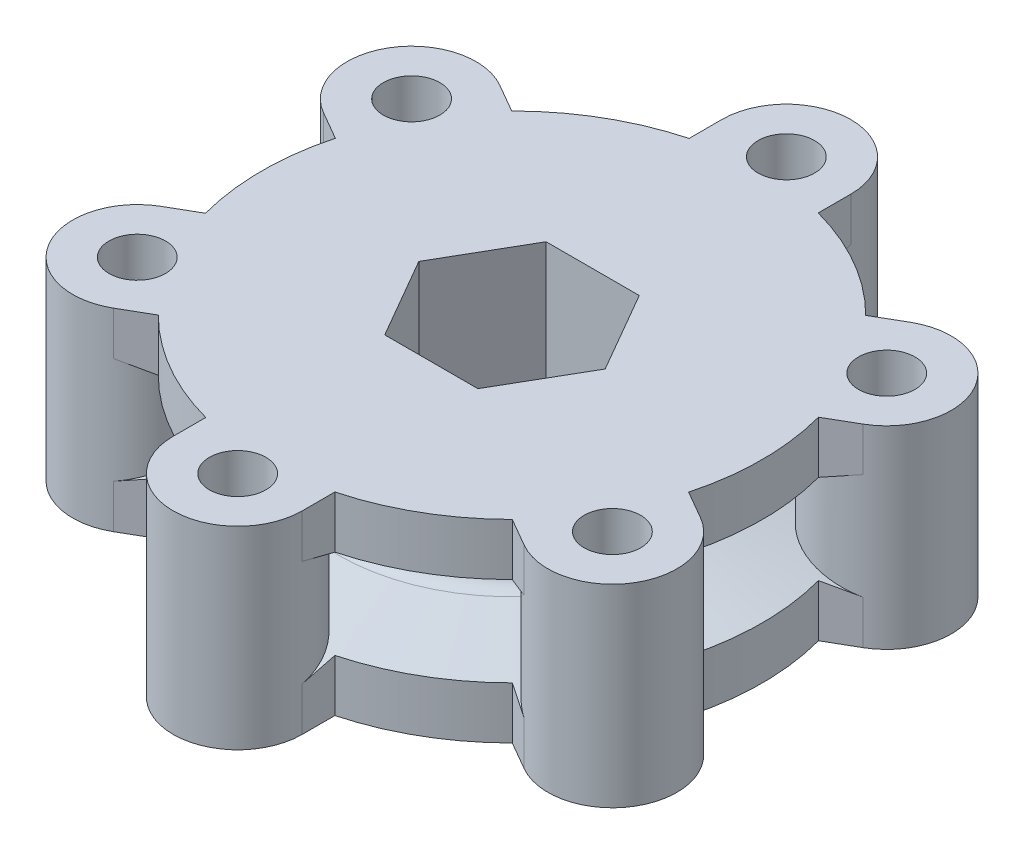
from build123d import *

# Parameters (mm, degrees)
SKETCH1_R           = 31.75
BOSS_EXTRUDE1_DEPTH = 7.62
CUT_EXTRUDE4_DEPTH  = 0.635
CIRPATTERN2_COUNT   = 20
BOSS_EXTRUDE2_REACH = 46.031
SKETCH5_R           = 5.08
SKETCH5_R_2         = 2.2225
BOSS_EXTRUDE6_REACH = 46.031
SKETCH12_R          = 5.08
SKETCH17_R          = 2.2225
CUT_EXTRUDE5_DEPTH  = 43.006102077
CIRPATTERN1_COUNT   = 3
BOSS_EXTRUDE9_REACH = 40.845
SKETCH18_R          = 12.7
FILLET5_R           = 1.27
CUT_EXTRUDE7_DEPTH  = 39.84476118


with BuildPart() as part:
    # Sketch1 → Boss-Extrude1 (new, symmetric)
    with BuildSketch(Plane(origin=(0, 0, 0), x_dir=(1, 0, 0), z_dir=(0, 1, 0))):
        Circle(SKETCH1_R)
    extrude(amount=BOSS_EXTRUDE1_DEPTH, both=True)

    # Sketch9 → Cut-Extrude4 (cut)
    with BuildSketch(Plane.ZY.offset(31.75)):
        Polygon((-0.635, -7.62), (0.635, -7.62), (0.635, 0), (0.635, 7.62), (-0.635, 7.62), (-0.635, 0), align=None)
    cut_extrude4 = extrude(amount=-CUT_EXTRUDE4_DEPTH, mode=Mode.SUBTRACT)

    # CirPattern2: Cut-Extrude4 ×20 about axis
    cirpattern2_axis = Axis((0, -7.62, 0), (0, 1, 0))
    for i in range(1, CIRPATTERN2_COUNT):
        add(cut_extrude4.rotate(cirpattern2_axis, i * 360 / CIRPATTERN2_COUNT), mode=Mode.SUBTRACT)

    # Sketch4 → Cut-Revolve2 (revolve, cut)
    with BuildSketch(Plane.XY):
        Polygon((-31.75, -7.62), (-29.21, -7.62), (-29.21, -6.0325), (-6.35, 0), (-29.21, 6.0325), (-29.21, 7.62), (-31.75, 7.62), align=None)
    revolve(axis=Axis((0, -9.0805, 0), (0, 1, 0)), mode=Mode.SUBTRACT)

    # Sketch5 → Boss-Extrude2 (add, up to next)
    with BuildSketch(Plane(origin=(0, 7.62, 0), x_dir=(1, 0, 0), z_dir=(0, 1, 0)), mode=Mode.PRIVATE) as boss_extrude2_sk1:
        with Locations((0, 21.59)):
            Circle(SKETCH5_R)
        with Locations((0, 21.59)):
            Circle(SKETCH5_R_2, mode=Mode.SUBTRACT)
    boss_extrude2_tool1 = extrude(boss_extrude2_sk1.sketch, amount=-BOSS_EXTRUDE2_REACH, mode=Mode.PRIVATE) - part.part
    boss_extrude2 = boss_extrude2_tool1.solids().sort_by_distance((-4.936316, 7.62, -21.59))[0]
    add(boss_extrude2)

    # Sketch12 → Boss-Extrude6 (add, up to next)
    with BuildSketch(Plane(origin=(0, 7.62, 0), x_dir=(1, 0, 0), z_dir=(0, 1, 0)), mode=Mode.PRIVATE) as boss_extrude6_sk1:
        with Locations((-18.697488468, 10.795)):
            Circle(SKETCH12_R)
    boss_extrude6_tool1 = extrude(boss_extrude6_sk1.sketch, amount=-BOSS_EXTRUDE6_REACH, mode=Mode.PRIVATE) - part.part
    boss_extrude6 = boss_extrude6_tool1.solids().sort_by_distance((-18.697488, 7.62, -10.795))[0]
    add(boss_extrude6)

    # Sketch17 → Cut-Extrude5 (cut, symmetric)
    with BuildSketch(Plane(origin=(0, 0, 0), x_dir=(1, 0, 0), z_dir=(0, 1, 0))):
        with Locations((0, 21.59)):
            Circle(SKETCH17_R)
        with Locations((-18.697488468, 10.795)):
            Circle(SKETCH17_R)
        with Locations((-18.697488468, -10.795)):
            Circle(SKETCH17_R)
        with BuildLine():
            Line((-23.096897519, -13.335), (-25.296602045, -14.605))
            ThreePointArc((-25.296602045, -14.605), (-25.296602045, 14.605), (0, 29.21))
            Line((0, 29.21), (0, 26.67))
            ThreePointArc((0, 26.67), (-3.592102448, 25.182102448), (-5.08, 21.59))
            Line((-5.08, 21.59), (-5.08, 19.018223497))
            ThreePointArc((-5.08, 19.018223497), (-9.8425, 17.047710073), (-13.930264684, 13.9085208))
            Line((-13.930264684, 13.9085208), (-16.157488468, 15.194409051))
            ThreePointArc((-16.157488468, 15.194409051), (-23.096897519, 13.335), (-21.237488468, 6.395590949))
            Line((-21.237488468, 6.395590949), (-19.010264684, 5.109702698))
            ThreePointArc((-19.010264684, 5.109702698), (-19.685, 0), (-19.010264684, -5.109702698))
            Line((-19.010264684, -5.109702698), (-21.237488468, -6.395590949))
            ThreePointArc((-21.237488468, -6.395590949), (-23.604391665, -9.480199251), (-23.096897519, -13.335))
        make_face()
    cut_extrude5 = extrude(amount=CUT_EXTRUDE5_DEPTH, both=True, mode=Mode.SUBTRACT)

    # CirPattern1: Boss-Extrude2, Boss-Extrude6, Cut-Extrude5 ×3 about axis
    cirpattern1_axis = Axis((0, 6.0325, 0), (0, -1, 0))
    add([boss_extrude2.rotate(cirpattern1_axis, i * 360 / CIRPATTERN1_COUNT) for i in range(1, CIRPATTERN1_COUNT)])
    add([boss_extrude6.rotate(cirpattern1_axis, i * 360 / CIRPATTERN1_COUNT) for i in range(1, CIRPATTERN1_COUNT)])
    add([cut_extrude5.rotate(cirpattern1_axis, i * 360 / CIRPATTERN1_COUNT) for i in range(1, CIRPATTERN1_COUNT)], mode=Mode.SUBTRACT)

    # Sketch18 → Boss-Extrude9 (add, up to next)
    with BuildSketch(Plane.XZ.offset(7.62), mode=Mode.PRIVATE) as boss_extrude9_sk1:
        Circle(SKETCH18_R)
    boss_extrude9_tool1 = extrude(boss_extrude9_sk1.sketch, amount=-BOSS_EXTRUDE9_REACH, mode=Mode.PRIVATE) - part.part
    add(boss_extrude9_tool1.solids().sort_by_distance((0, -7.62, 0))[0])

    # Fillet5
    fillet5_edges = [part.edges().sort_by_distance(p)[0] for p in [
        (0, -1.675694444, -12.7),
        (0, 1.675694444, 12.7),
    ]]
    fillet(fillet5_edges, radius=FILLET5_R)

    # Sketch24 → Cut-Extrude7 (cut, through all)
    with BuildSketch(Plane.XZ.offset(7.62)):
        Polygon((3.666174209, -6.35), (7.332348419, 0), (3.666174209, 6.35), (-3.666174209, 6.35), (-7.332348419, 0), (-3.666174209, -6.35), align=None)
    extrude(amount=-CUT_EXTRUDE7_DEPTH, mode=Mode.SUBTRACT)


solid = part.part
